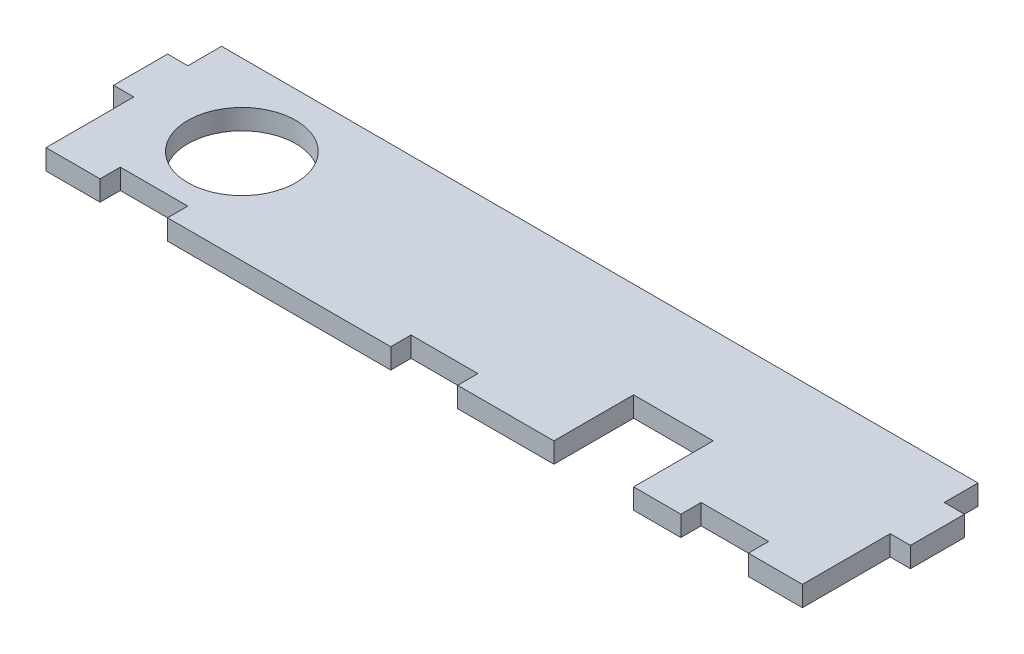
from build123d import *

# Parameters (mm, degrees)
SKETCH1_R           = 8
BOSS_EXTRUDE1_DEPTH = 3


with BuildPart() as part:
    # Sketch1 → Boss-Extrude1 (new body)
    with BuildSketch(Plane(origin=(0, 0, 0), x_dir=(1, 0, 0), z_dir=(0, 1, 0))):
        Polygon((1213.408125786, -2432.393668664), (1216.408125786, -2432.393668664), (1216.408125786, -2424.393668664), (1213.408125786, -2424.393668664), (1213.408125786, -2419.393668664), (1101.408125786, -2419.393668664), (1101.408125786, -2424.393668664), (1098.408125786, -2424.393668664), (1098.408125786, -2432.393668664), (1101.408125786, -2432.393668664), (1101.408125786, -2445.393668664), (1109.408125786, -2445.393668664), (1109.408125786, -2442.393668664), (1119.408125786, -2442.393668664), (1119.408125786, -2445.393668664), (1152.458125786, -2445.393668664), (1152.458125786, -2442.393668664), (1162.358125786, -2442.393668664), (1162.358125786, -2445.393668664), (1176.608125786, -2445.393668664), (1176.608125786, -2433.593668664), (1188.408125786, -2433.593668664), (1188.408125786, -2445.393668664), (1195.408125786, -2445.393668664), (1195.408125786, -2442.393668664), (1205.408125786, -2442.393668664), (1205.408125786, -2445.393668664), (1213.408125786, -2445.393668664), align=None)
        with Locations((1116.408125786, -2431.393668664)):
            Circle(SKETCH1_R, mode=Mode.SUBTRACT)
    extrude(amount=BOSS_EXTRUDE1_DEPTH)


solid = part.part
